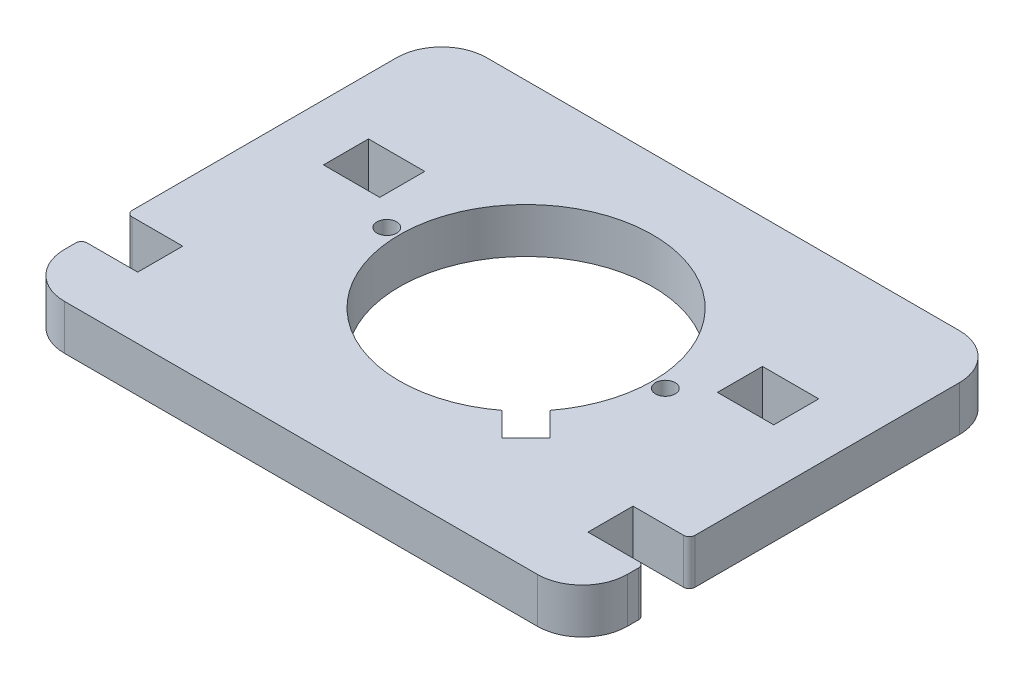
from build123d import *

# Parameters (mm, degrees)
SKETCH1_W           = 10
SKETCH1_H           = 8
SKETCH1_R           = 1.75
BOSS_EXTRUDE2_DEPTH = 8


with BuildPart() as part:
    # Sketch1 → Boss-Extrude2 (new body)
    with BuildSketch(Plane(origin=(0, 0, 0), x_dir=(1, 0, 0), z_dir=(0, 1, 0))):
        with BuildLine():
            Line((-92, 0), (-8, 0))
            ThreePointArc((-8, 0), (-2.343145751, 2.343145751), (0, 8))
            Line((0, 8), (0, 10))
            ThreePointArc((0, 10), (-0.292893219, 10.707106781), (-1, 11))
            Line((-1, 11), (-10, 11))
            Line((-10, 11), (-10, 19))
            Line((-10, 19), (-1, 19))
            ThreePointArc((-1, 19), (-0.292893219, 19.292893219), (0, 20))
            Line((0, 20), (0, 67))
            ThreePointArc((0, 67), (-2.343145751, 72.656854249), (-8, 75))
            Line((-8, 75), (-92, 75))
            ThreePointArc((-92, 75), (-97.656854249, 72.656854249), (-100, 67))
            Line((-100, 67), (-100, 20))
            ThreePointArc((-100, 20), (-99.707106781, 19.292893219), (-99, 19))
            Line((-99, 19), (-90, 19))
            Line((-90, 19), (-90, 11))
            Line((-90, 11), (-99, 11))
            ThreePointArc((-99, 11), (-99.707106781, 10.707106781), (-100, 10))
            Line((-100, 10), (-100, 8))
            ThreePointArc((-100, 8), (-97.656854249, 2.343145751), (-92, 0))
        make_face()
        with Locations((-85, 48)):
            Rectangle(SKETCH1_W, SKETCH1_H, mode=Mode.SUBTRACT)
        with Locations((-15, 48)):
            Rectangle(SKETCH1_W, SKETCH1_H, mode=Mode.SUBTRACT)
        with Locations((-74.74, 40)):
            Circle(SKETCH1_R, mode=Mode.SUBTRACT)
        with BuildLine():
            Line((-32.110832625, 17.868191938), (-36.353473312, 22.110832625))
            ThreePointArc((-36.353473312, 22.110832625), (-65.909902577, 55.909902577), (-32.110832625, 26.353473312))
            Line((-32.110832625, 26.353473312), (-27.868191938, 22.110832625))
            Line((-27.868191938, 22.110832625), (-32.110832625, 17.868191938))
        make_face(mode=Mode.SUBTRACT)
        with Locations((-25.26, 40)):
            Circle(SKETCH1_R, mode=Mode.SUBTRACT)
    extrude(amount=BOSS_EXTRUDE2_DEPTH)


solid = part.part
